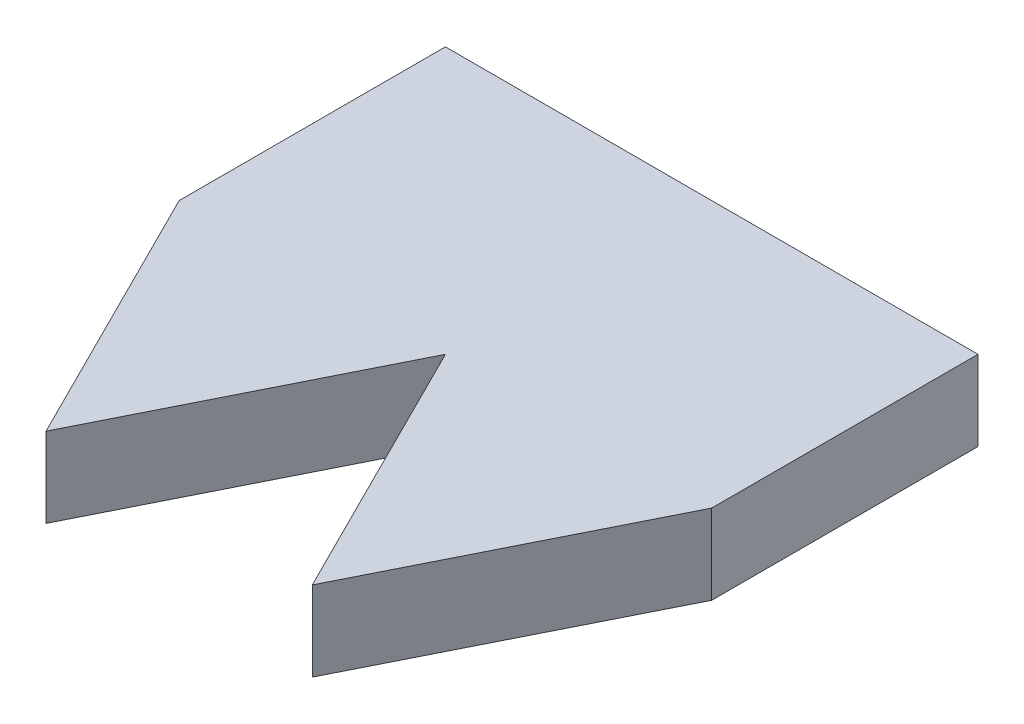
from build123d import *

# Parameters (mm, degrees)
SKETCH1_W               = 20
SKETCH1_H               = 20
BOSS_EXTRUDE1_DEPTH     = 3
CUT_EXTRUDE1_DEPTH      = 1
CUT_EXTRUDE1_DEPTH_BACK = 4


with BuildPart() as part:
    # Sketch1 → Boss-Extrude1 (new body)
    with BuildSketch(Plane(origin=(0, 0, 0), x_dir=(1, 0, 0), z_dir=(0, 1, 0))):
        Rectangle(SKETCH1_W, SKETCH1_H)
    extrude(amount=BOSS_EXTRUDE1_DEPTH)

    # Sketch2 → Cut-Extrude1 (cut, two sides)
    with BuildSketch(Plane(origin=(0, 3, 0), x_dir=(1, 0, 0), z_dir=(0, 1, 0))) as cut_extrude1_sk:
        Polygon((-5, -10), (-10, 0), (-10, -10), align=None)
        Polygon((0, 0), (-5, -10), (5, -10), align=None)
        Polygon((10, 0), (5, -10), (10, -10), align=None)
    extrude(amount=CUT_EXTRUDE1_DEPTH, mode=Mode.SUBTRACT)
    extrude(cut_extrude1_sk.sketch, amount=-CUT_EXTRUDE1_DEPTH_BACK, mode=Mode.SUBTRACT)


solid = part.part
